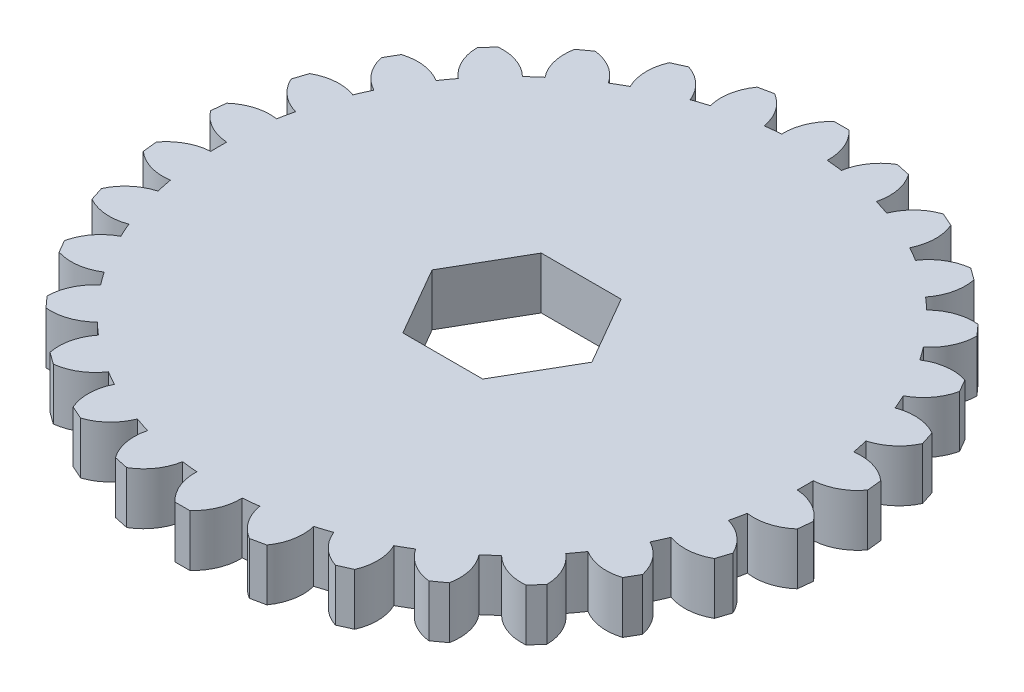
from build123d import *

# Parameters (mm, degrees)
SKETCH2_R           = 26.923711167
BOSS_EXTRUDE2_DEPTH = 4.7625
BOSS_EXTRUDE3_DEPTH = 4.7625
CIRPATTERN1_COUNT   = 30


with BuildPart() as part:
    # Sketch2 → Boss-Extrude2 (new body)
    with BuildSketch(Plane(origin=(0, 0, 0), x_dir=(1, 0, 0), z_dir=(0, 1, 0))):
        Circle(SKETCH2_R)
        Polygon((7.332348419, 0), (3.666174209, 6.35), (-3.666174209, 6.35), (-7.332348419, 0), (-3.666174209, -6.35), (3.666174209, -6.35), align=None, mode=Mode.SUBTRACT)
    extrude(amount=BOSS_EXTRUDE2_DEPTH)

    # Sketch1 → Boss-Extrude3 (add)
    with BuildSketch(Plane(origin=(0, 0, 0), x_dir=(1, 0, 0), z_dir=(0, 1, 0))):
        with BuildLine():
            Line((0.673251408, 30.249487652), (-0.673251408, 30.249487652))
            ThreePointArc((-0.673251408, 30.249487652), (-1.756386228, 28.702610818), (-2.084301351, 26.842911743))
            ThreePointArc((-2.084301351, 26.842911743), (0, 26.923711167), (2.084301351, 26.842911743))
            ThreePointArc((2.084301351, 26.842911743), (1.756386228, 28.702610818), (0.673251408, 30.249487652))
        make_face()
    boss_extrude3 = extrude(amount=BOSS_EXTRUDE3_DEPTH)

    # CirPattern1: Boss-Extrude3 ×30 about axis
    cirpattern1_axis = Axis((0, 0, 0), (0, 1, 0))
    for i in range(1, CIRPATTERN1_COUNT):
        add(boss_extrude3.rotate(cirpattern1_axis, i * 360 / CIRPATTERN1_COUNT))


solid = part.part
